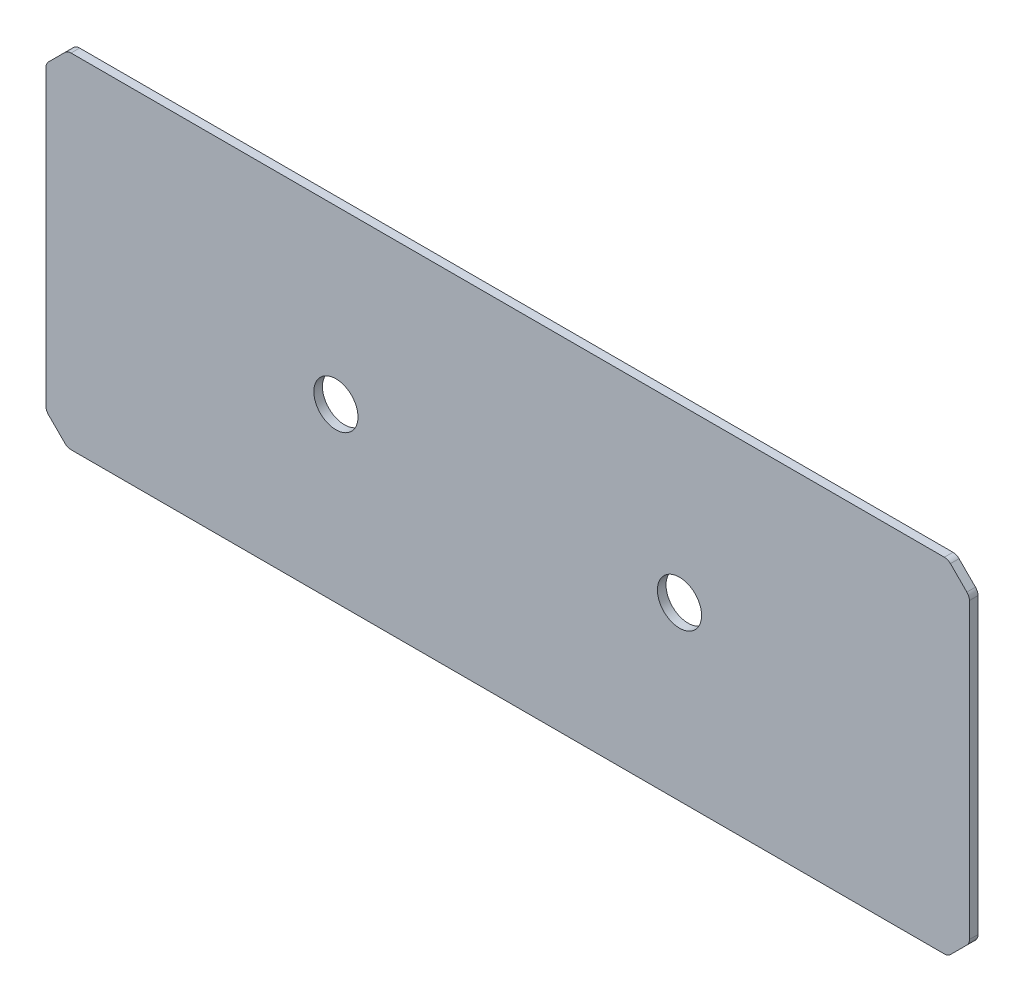
from build123d import *

# Parameters (mm, degrees)
SKETCH1_W           = 136.525
SKETCH1_H           = 50.8
BOSS_EXTRUDE1_DEPTH = 1.27
SKETCH3_R           = 3.2639
CUT_EXTRUDE1_DEPTH  = 2.27
CHAMFER1_SIZE       = 3.175
FILLET1_R           = 1.27


with BuildPart() as part:
    # Sketch1 → Boss-Extrude1 (new body)
    with BuildSketch(Plane.XY):
        with Locations((68.2625, 25.4)):
            Rectangle(SKETCH1_W, SKETCH1_H)
    extrude(amount=BOSS_EXTRUDE1_DEPTH)

    # Sketch3 → Cut-Extrude1 (cut, through all)
    with BuildSketch(Plane.XY.offset(1.27)):
        with Locations((93.6625, 25.4)):
            Circle(SKETCH3_R)
        with Locations((42.8625, 25.4)):
            Circle(SKETCH3_R)
    extrude(amount=-CUT_EXTRUDE1_DEPTH, mode=Mode.SUBTRACT)

    # Chamfer1
    chamfer1_edges = [part.edges().sort_by_distance(p)[0] for p in [
        (0, 0, 0.635),
        (0, 50.8, 0.635),
        (136.525, 50.8, 0.635),
        (136.525, 0, 0.635),
    ]]
    chamfer(chamfer1_edges, length=CHAMFER1_SIZE)

    # Fillet1
    fillet1_edges = [part.edges().sort_by_distance(p)[0] for p in [
        (133.35, 0, 0.635),
        (3.175, 0, 0.635),
        (0, 47.625, 0.635),
        (0, 3.175, 0.635),
        (133.35, 50.8, 0.635),
        (3.175, 50.8, 0.635),
        (136.525, 3.175, 0.635),
        (136.525, 47.625, 0.635),
    ]]
    fillet(fillet1_edges, radius=FILLET1_R)


solid = part.part
